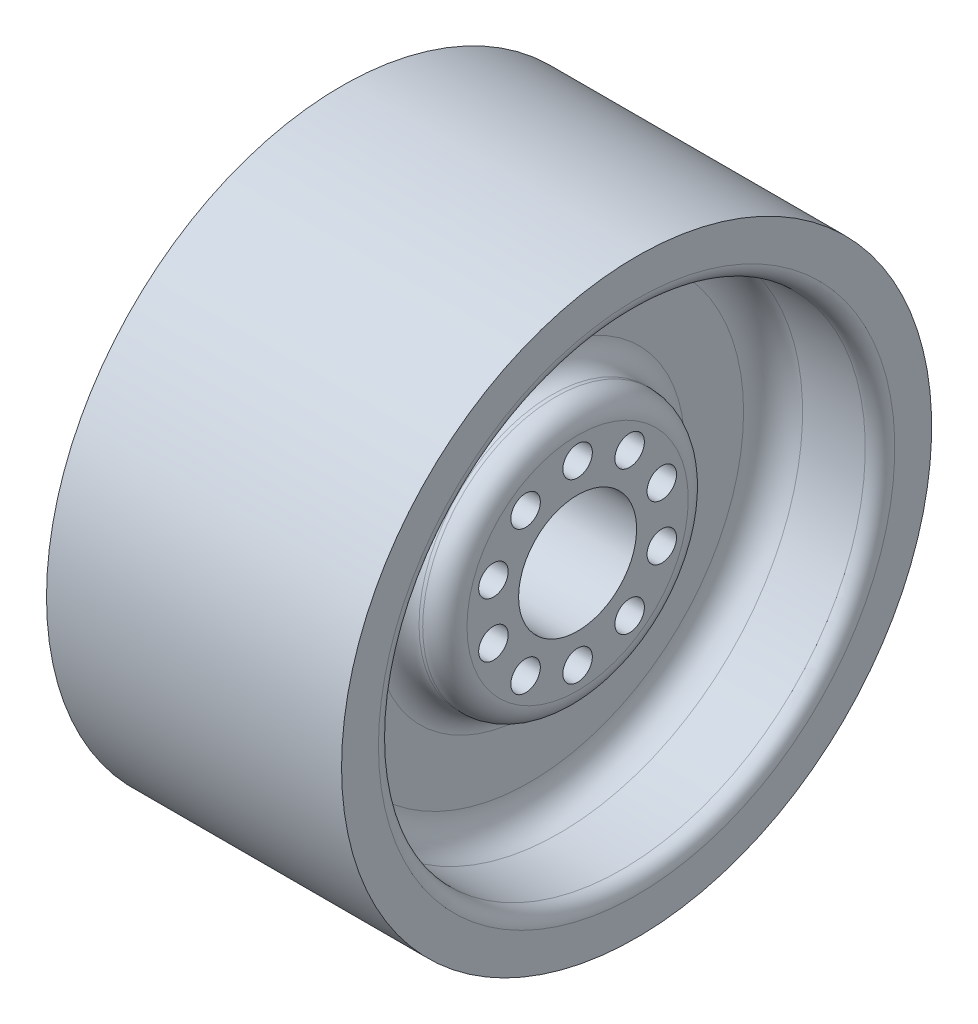
from build123d import *

# Parameters (mm, degrees)
SKETCH4_R          = 40
SKETCH4_R_2        = 10
CUT_EXTRUDE2_DEPTH = 161


with BuildPart() as part:
    # Sketch2 → Revolve1 (revolve)
    with BuildSketch(Plane.XY):
        with BuildLine():
            Line((40, 0), (160, 0))
            Line((160, 0), (160, 75))
            ThreePointArc((160, 75), (155.606601718, 85.606601718), (145, 90))
            Line((145, 90), (142.5, 90))
            ThreePointArc((142.5, 90), (131.893398282, 94.393398282), (127.5, 105))
            Line((127.5, 105), (127.5, 145.001))
            ThreePointArc((127.5, 145.001), (133.357864376, 159.143135624), (147.5, 165.001))
            Line((147.5, 165.001), (190, 165.001))
            ThreePointArc((190, 165.001), (197.071067812, 167.929932188), (200, 175.001))
            Line((200, 175.001), (200, 200.001))
            Line((200, 200.001), (0, 200.001))
            Line((0, 200.001), (0, 175.001))
            ThreePointArc((0, 175.001), (2.928932188, 167.929932188), (10, 165.001))
            Line((10, 165.001), (52.5, 165.001))
            ThreePointArc((52.5, 165.001), (66.642135624, 159.143135624), (72.5, 145.001))
            Line((72.5, 145.001), (72.5, 105))
            ThreePointArc((72.5, 105), (68.106601718, 94.393398282), (57.5, 90))
            Line((57.5, 90), (55, 90))
            ThreePointArc((55, 90), (44.393398282, 85.606601718), (40, 75))
            Line((40, 75), (40, 0))
        make_face()
    revolve(axis=Axis((40, 0, 0), (1, 0, 0)))

    # Sketch4 → Cut-Extrude2 (cut, through all)
    with BuildSketch(Plane.ZY.offset(-40)):
        Circle(SKETCH4_R)
        with Locations((0, 60)):
            Circle(SKETCH4_R_2)
        with Locations((35.267115138, 48.541019662)):
            Circle(SKETCH4_R_2)
        with Locations((57.063390978, 18.541019662)):
            Circle(SKETCH4_R_2)
        with Locations((57.063390978, -18.541019662)):
            Circle(SKETCH4_R_2)
        with Locations((35.267115138, -48.541019662)):
            Circle(SKETCH4_R_2)
        with Locations((0, -60)):
            Circle(SKETCH4_R_2)
        with Locations((-35.267115138, -48.541019662)):
            Circle(SKETCH4_R_2)
        with Locations((-57.063390978, -18.541019662)):
            Circle(SKETCH4_R_2)
        with Locations((-57.063390978, 18.541019662)):
            Circle(SKETCH4_R_2)
        with Locations((-35.267115138, 48.541019662)):
            Circle(SKETCH4_R_2)
    extrude(amount=-CUT_EXTRUDE2_DEPTH, mode=Mode.SUBTRACT)


solid = part.part
